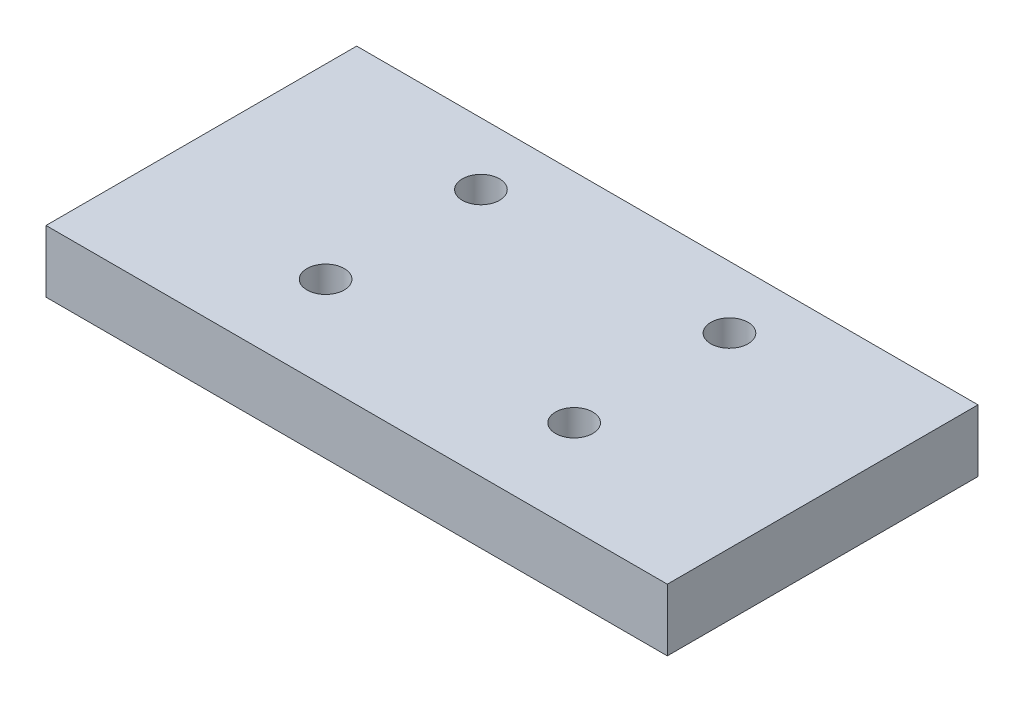
from build123d import *

# Parameters (mm, degrees)
SKETCH1_W           = 100
SKETCH1_H           = 50
SKETCH1_R           = 3
BOSS_EXTRUDE1_DEPTH = 10


with BuildPart() as part:
    # Sketch1 → Boss-Extrude1 (new body)
    with BuildSketch(Plane(origin=(0, 0, 0), x_dir=(1, 0, 0), z_dir=(0, 1, 0))):
        with Locations((50, 25)):
            Rectangle(SKETCH1_W, SKETCH1_H)
        with Locations((70, 15)):
            Circle(SKETCH1_R, mode=Mode.SUBTRACT)
        with Locations((30, 15)):
            Circle(SKETCH1_R, mode=Mode.SUBTRACT)
        with Locations((30, 40)):
            Circle(SKETCH1_R, mode=Mode.SUBTRACT)
        with Locations((70, 40)):
            Circle(SKETCH1_R, mode=Mode.SUBTRACT)
    extrude(amount=BOSS_EXTRUDE1_DEPTH)


solid = part.part
